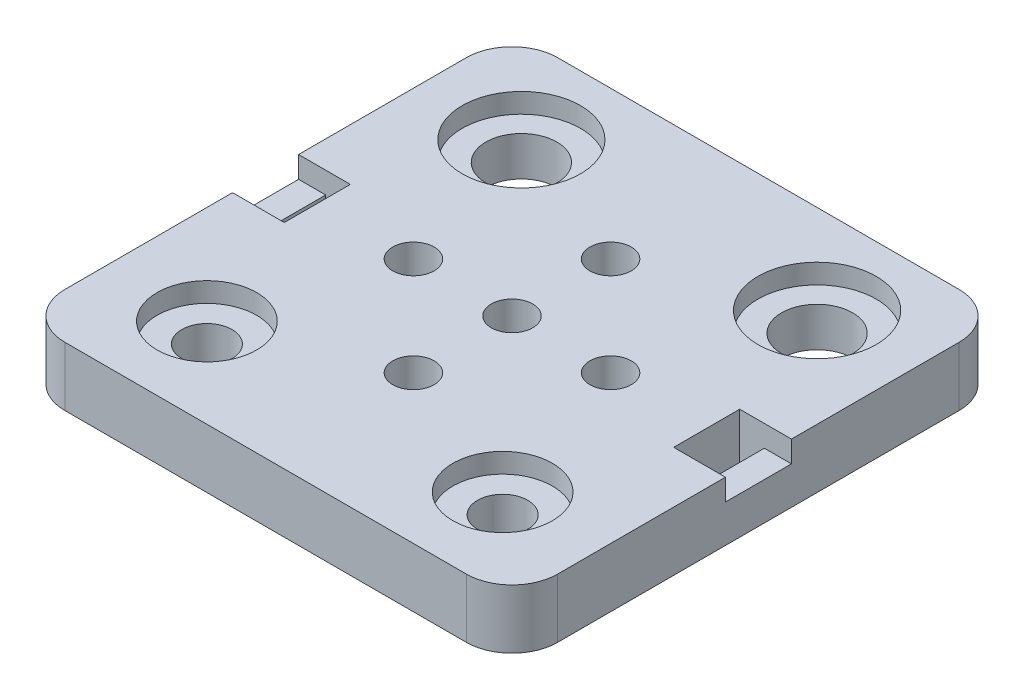
from build123d import *

# Parameters (mm, degrees)
SKETCH1_R             = 3.6
SKETCH1_R_2           = 2.55
BOSS_EXTRUDE1_DEPTH   = 6
M5X0_8_TAPPED_HOLE1_D = 4.2
SKETCH2_R             = 6
SKETCH2_R_2           = 5.05
CUT_EXTRUDE1_DEPTH    = 2
SKETCH5_W             = 5.25
SKETCH5_H             = 6.7
CUT_EXTRUDE2_DEPTH    = 2.18
SKETCH6_W             = 2.5
SKETCH6_H             = 6.7
CUT_EXTRUDE3_DEPTH    = 4.82


with BuildPart() as part:
    # Sketch1 → Boss-Extrude1 (new body)
    with BuildSketch(Plane(origin=(0, 0, 0), x_dir=(1, 0, 0), z_dir=(0, 1, 0))):
        with BuildLine():
            Line((20.365, -25), (-20.365, -25))
            ThreePointArc((-20.365, -25), (-23.642439931, -23.642439931), (-25, -20.365))
            Line((-25, -20.365), (-25, 20.365))
            ThreePointArc((-25, 20.365), (-23.642439931, 23.642439931), (-20.365, 25))
            Line((-20.365, 25), (20.365, 25))
            ThreePointArc((20.365, 25), (23.642439931, 23.642439931), (25, 20.365))
            Line((25, 20.365), (25, -20.365))
            ThreePointArc((25, -20.365), (23.642439931, -23.642439931), (20.365, -25))
        make_face()
        with Locations((-15, 15.95)):
            Circle(SKETCH1_R, mode=Mode.SUBTRACT)
        with Locations((15, 15.95)):
            Circle(SKETCH1_R, mode=Mode.SUBTRACT)
        with Locations((15, -15.95)):
            Circle(SKETCH1_R_2, mode=Mode.SUBTRACT)
        with Locations((-15, -15.95)):
            Circle(SKETCH1_R_2, mode=Mode.SUBTRACT)
    extrude(amount=BOSS_EXTRUDE1_DEPTH)

    # M5x0.8 Tapped Hole1 (through all)
    with Locations(Plane(origin=(0, 6, 0), x_dir=(1, 0, 0), z_dir=(0, 1, 0))):
        with Locations((0, 10), (-10, 0), (0, 0), (0, -10), (10, 0)):
            Hole(M5X0_8_TAPPED_HOLE1_D / 2)

    # Sketch2 → Cut-Extrude1 (cut)
    with BuildSketch(Plane(origin=(0, 6, 0), x_dir=(1, 0, 0), z_dir=(0, 1, 0))):
        with Locations((-15, 15.95)):
            Circle(SKETCH2_R)
        with Locations((15, 15.95)):
            Circle(SKETCH2_R)
        with Locations((15, -15.95)):
            Circle(SKETCH2_R_2)
        with Locations((-15, -15.95)):
            Circle(SKETCH2_R_2)
    extrude(amount=-CUT_EXTRUDE1_DEPTH, mode=Mode.SUBTRACT)

    # Sketch5 → Cut-Extrude2 (cut)
    with BuildSketch(Plane(origin=(0, 6, 0), x_dir=(1, 0, 0), z_dir=(0, 1, 0))):
        with Locations((-22.375, 0)):
            Rectangle(SKETCH5_W, SKETCH5_H)
        with Locations((22.375, 0)):
            Rectangle(SKETCH5_W, SKETCH5_H)
    extrude(amount=-CUT_EXTRUDE2_DEPTH, mode=Mode.SUBTRACT)

    # Sketch6 → Cut-Extrude3 (cut, through all)
    with BuildSketch(Plane(origin=(0, 3.82, 0), x_dir=(1, 0, 0), z_dir=(0, 1, 0))):
        with Locations((-21, 0)):
            Rectangle(SKETCH6_W, SKETCH6_H)
        with Locations((21, 0)):
            Rectangle(SKETCH6_W, SKETCH6_H)
    extrude(amount=-CUT_EXTRUDE3_DEPTH, mode=Mode.SUBTRACT)


solid = part.part
